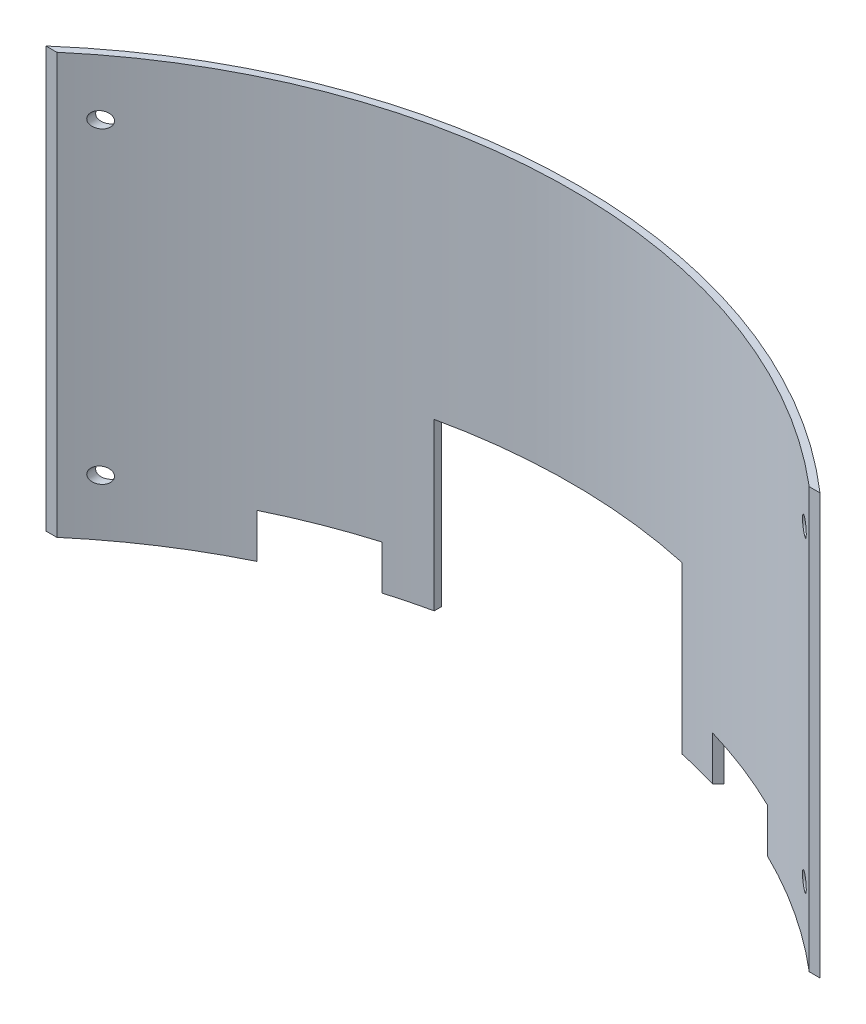
from build123d import *

# Parameters (mm, degrees)
CURVED_PLATE_DEPTH      = 190
IR_CUTOUT_DEPTH         = 20
CHARGERBOX_CUTOUT_REACH = 67.75
SKETCH3_W               = 112
SKETCH3_H               = 75
SKETCH5_R               = 3.5687
MOUNTING_HOLES_DEPTH    = 66.75


with BuildPart() as part:
    # Sketch1 → Curved Plate (new body)
    with BuildSketch(Plane(origin=(0, 0, 0), x_dir=(1, 0, 0), z_dir=(0, 1, 0))):
        with BuildLine():
            Line((170.139573777, 0), (175, 0))
            ThreePointArc((175, 0), (0, 65.75), (-175, 0))
            Line((-175, 0), (-170.139573777, 0))
            ThreePointArc((-170.139573777, 0), (0, 62.575), (170.139573777, 0))
        make_face()
    extrude(amount=CURVED_PLATE_DEPTH)

    # Sketch2 → IR Cutout (cut)
    with BuildSketch(Plane(origin=(0, 0, 0), x_dir=(1, 0, 0), z_dir=(0, 1, 0))):
        with BuildLine():
            Line((-117.762328859, 38.234983169), (-105.521942389, 25.994596699))
            Line((-105.521942389, 25.994596699), (-101.986408483, 22.459062793))
            Line((-101.986408483, 22.459062793), (-73.702137236, 50.743334041))
            Line((-73.702137236, 50.743334041), (-77.237671141, 54.278867947))
            ThreePointArc((-77.237671141, 54.278867947), (-97.829451392, 47.089074697), (-117.762328859, 38.234983169))
        make_face()
        with BuildLine():
            Line((77.237671141, 54.278867947), (73.702137236, 50.743334041))
            Line((73.702137236, 50.743334041), (101.986408483, 22.459062793))
            Line((101.986408483, 22.459062793), (105.521942389, 25.994596699))
            Line((105.521942389, 25.994596699), (117.762328859, 38.234983169))
            ThreePointArc((117.762328859, 38.234983169), (97.829451392, 47.089074697), (77.237671141, 54.278867947))
        make_face()
    extrude(amount=IR_CUTOUT_DEPTH, mode=Mode.SUBTRACT)

    # Sketch3 → ChargerBox Cutout (cut, up to next)
    with BuildSketch(Plane.XY, mode=Mode.PRIVATE) as chargerbox_cutout_sk1:
        with Locations((0, 37.5)):
            Rectangle(SKETCH3_W, SKETCH3_H)
    chargerbox_cutout_tool1 = extrude(chargerbox_cutout_sk1.sketch, amount=-CHARGERBOX_CUTOUT_REACH, mode=Mode.PRIVATE) & part.part
    add(chargerbox_cutout_tool1.solids().sort_by_distance((0, 37.5, 0))[0], mode=Mode.SUBTRACT)

    # Sketch5 → Mounting Holes (cut, through all)
    with BuildSketch(Plane.XY):
        with Locations((-159.125, 164.6)):
            Circle(SKETCH5_R)
        with Locations((-159.125, 25.4)):
            Circle(SKETCH5_R)
        with Locations((159.125, 25.4)):
            Circle(SKETCH5_R)
        with Locations((159.125, 164.6)):
            Circle(SKETCH5_R)
    extrude(amount=-MOUNTING_HOLES_DEPTH, mode=Mode.SUBTRACT)


solid = part.part
